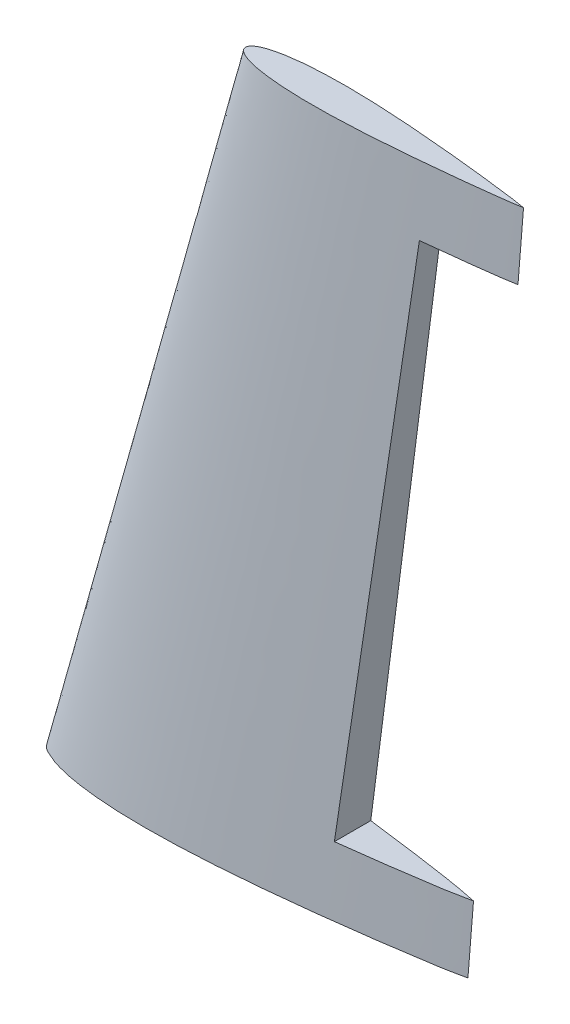
from build123d import *

# Parameters (mm, degrees)
CUT_EXTRUDE1_DEPTH      = 303.533691694
CUT_EXTRUDE1_DEPTH_BACK = 303.533691694


with BuildPart() as part:
    # Sketch2 → Loft1 section 0
    with BuildSketch(Plane(origin=(0, 0, 0), x_dir=(1, 0, 0), z_dir=(0, 1, 0))):
        with BuildLine():
            add(Edge.make_bspline(
                [(0, 0), (0.357433553, 1.567842951), (1.917970176, 4.160229764), (5.97481653, 6.081249697), (9.685317154, 7.498428782), (13.560078119, 8.488450032), (17.359013279, 9.274437737), (21.537080113, 9.926762724), (26.46178465, 10.495714484), (33.030088427, 11.004191676), (39.777903449, 11.237535202), (48.881830343, 11.276440135), (58.76193613, 11.001555412), (68.683481214, 10.411026067), (82.689863985, 9.343738865), (94.136580366, 8.168132094), (108.892414504, 6.408281033), (116.550975745, 5.416254952), (123.975633155, 4.354289335), (127.960081342, 3.77052037), (132.393799107, 3.105793902), (137.115401047, 2.40243394), (143.03529364, 1.468316053), (147.203728737, 0.596703087), (150, 0)],
                knots=[0, 0, 0, 0, 0.031271315, 0.055076604, 0.085653186, 0.108857761, 0.132714605, 0.161157924, 0.191102095, 0.229169149, 0.289322728, 0.322456152, 0.406317058, 0.481621487, 0.515848821, 0.679661265, 0.705502791, 0.805025067, 0.829931294, 0.851453308, 0.883388416, 0.917173131, 0.944349664, 1, 1, 1, 1], degree=3))
            add(Edge.make_bspline(
                [(0, 0), (0.394064241, -1.54877785), (1.863432045, -4.108329327), (5.28724909, -5.736171), (8.233222924, -6.999318685), (11.439608234, -7.961073986), (14.837636919, -8.774678376), (18.226738528, -9.412867336), (21.607899865, -9.923992079), (25.17739935, -10.35155024), (30.263863608, -10.813990829), (36.567415813, -11.154786303), (45.633644275, -11.313399436), (54.659951216, -11.138633145), (65.729134774, -10.617890693), (80.628353886, -9.553465623), (94.39151788, -8.136116187), (108.235367187, -6.487796867), (115.481434177, -5.556138542), (124.038094924, -4.350742236), (129.185840061, -3.589034499), (134.229817914, -2.830310801), (137.671437841, -2.315360587), (140.909856219, -1.801519139), (145.017744862, -1.058252808), (147.972088501, -0.42879218), (150, 0)],
                knots=[0, 0, 0, 0, 0.031458743, 0.053377779, 0.072332266, 0.094059262, 0.118322991, 0.140338064, 0.161137525, 0.18485863, 0.210283619, 0.260514048, 0.30767032, 0.386712656, 0.436156502, 0.523300177, 0.677353161, 0.705359806, 0.794596405, 0.819513727, 0.8735115, 0.895859044, 0.9187711, 0.941229566, 0.959662244, 1, 1, 1, 1], degree=3))
        make_face()
    # Sketch3 → Loft1 section 1
    with BuildSketch(Plane(origin=(0, 250, 0), x_dir=(1, 0, 0), z_dir=(0, 1, 0))):
        with BuildLine():
            add(Edge.make_bspline(
                [(70, 0), (69.998695985, 0.55955733), (70.442205932, 1.260933045), (71.2121543, 1.885639789), (72.176569209, 2.500244125), (73.360859293, 3.018557927), (75.122720532, 3.618750694), (76.659068738, 4.023634354), (78.453879641, 4.413670772), (80.755673074, 4.834011856), (83.864457382, 5.25286849), (87.961435036, 5.633828774), (93.124785839, 5.92406083), (99.760074537, 6.045439608), (107.468637421, 5.921147675), (115.967916909, 5.556531892), (125.064057366, 4.966684256), (134.169678192, 4.212287311), (143.356076333, 3.327498387), (150.536726311, 2.550254072), (156.205971927, 1.886416966), (159.803934974, 1.44813753), (164.387726212, 0.858989173), (167.770673402, 0.429320596), (170, 0)],
                knots=[0, 0, 0, 0, 0.015533955, 0.02314791, 0.028948177, 0.048950772, 0.060740409, 0.083424122, 0.095372754, 0.114483795, 0.151867659, 0.187126741, 0.23485952, 0.303156584, 0.381272081, 0.460411987, 0.552057215, 0.647968854, 0.727745971, 0.822090373, 0.859296949, 0.894761026, 0.928143313, 0.994524953, 0.994524953, 0.994524953, 0.994524953], degree=3))
            add(Edge.make_bspline(
                [(70, 0), (69.998695985, -0.55955733), (70.442205932, -1.260933045), (71.2121543, -1.885639789), (72.176569209, -2.500244125), (73.360859293, -3.018557927), (75.122720532, -3.618750694), (76.659068738, -4.023634354), (78.453879641, -4.413670772), (80.755673074, -4.834011856), (83.864457382, -5.25286849), (87.961435036, -5.633828774), (93.124785839, -5.92406083), (99.760074537, -6.045439608), (107.468637421, -5.921147675), (115.967916909, -5.556531892), (125.064057366, -4.966684256), (134.169678192, -4.212287311), (143.356076333, -3.327498387), (150.536726311, -2.550254072), (156.205971927, -1.886416966), (159.803934974, -1.44813753), (164.387726212, -0.858989173), (167.770673402, -0.429320596), (170, 0)],
                knots=[0, 0, 0, 0, 0.015533955, 0.02314791, 0.028948177, 0.048950772, 0.060740409, 0.083424122, 0.095372754, 0.114483795, 0.151867659, 0.187126741, 0.23485952, 0.303156584, 0.381272081, 0.460411987, 0.552057215, 0.647968854, 0.727745971, 0.822090373, 0.859296949, 0.894761026, 0.928143313, 0.994524953, 0.994524953, 0.994524953, 0.994524953], degree=3))
        make_face()
    loft()

    # Sketch4 → Cut-Extrude1 (cut, two sides: drawn at the far end of the back side and taken through both)
    with BuildSketch(Plane.XY.offset(-CUT_EXTRUDE1_DEPTH_BACK)):
        Polygon((152, 25), (108.5, 25), (136.5, 225), (168, 225), align=None)
    extrude(amount=CUT_EXTRUDE1_DEPTH + CUT_EXTRUDE1_DEPTH_BACK, mode=Mode.SUBTRACT)


solid = part.part
